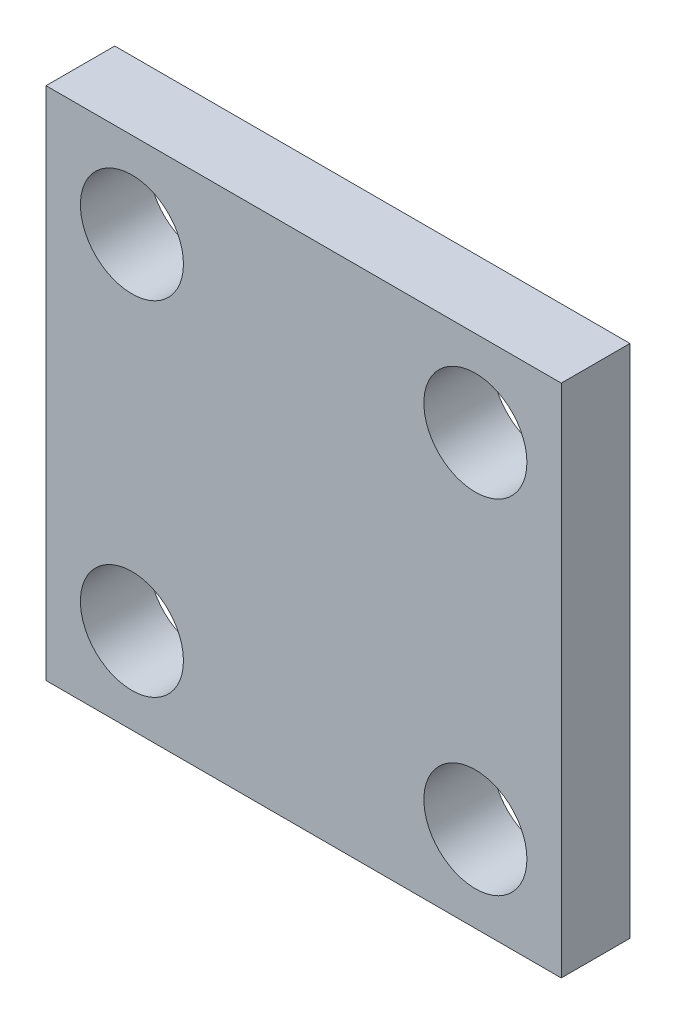
from build123d import *

# Parameters (mm, degrees)
ESQUISSE3_W        = 60
ESQUISSE3_H        = 60
ESQUISSE3_R        = 6
BOSS_EXTRU_4_DEPTH = 8


with BuildPart() as part:
    # Esquisse3 → Boss.-Extru.4 (new body)
    with BuildSketch(Plane.XY):
        Rectangle(ESQUISSE3_W, ESQUISSE3_H)
        with Locations((-19.999999157, 19.999999157)):
            Circle(ESQUISSE3_R, mode=Mode.SUBTRACT)
        with Locations((20.000000843, 20.000000843)):
            Circle(ESQUISSE3_R, mode=Mode.SUBTRACT)
        with Locations((-20.000000843, -20.000000843)):
            Circle(ESQUISSE3_R, mode=Mode.SUBTRACT)
        with Locations((19.999999157, -19.999999157)):
            Circle(ESQUISSE3_R, mode=Mode.SUBTRACT)
    extrude(amount=BOSS_EXTRU_4_DEPTH)


solid = part.part
